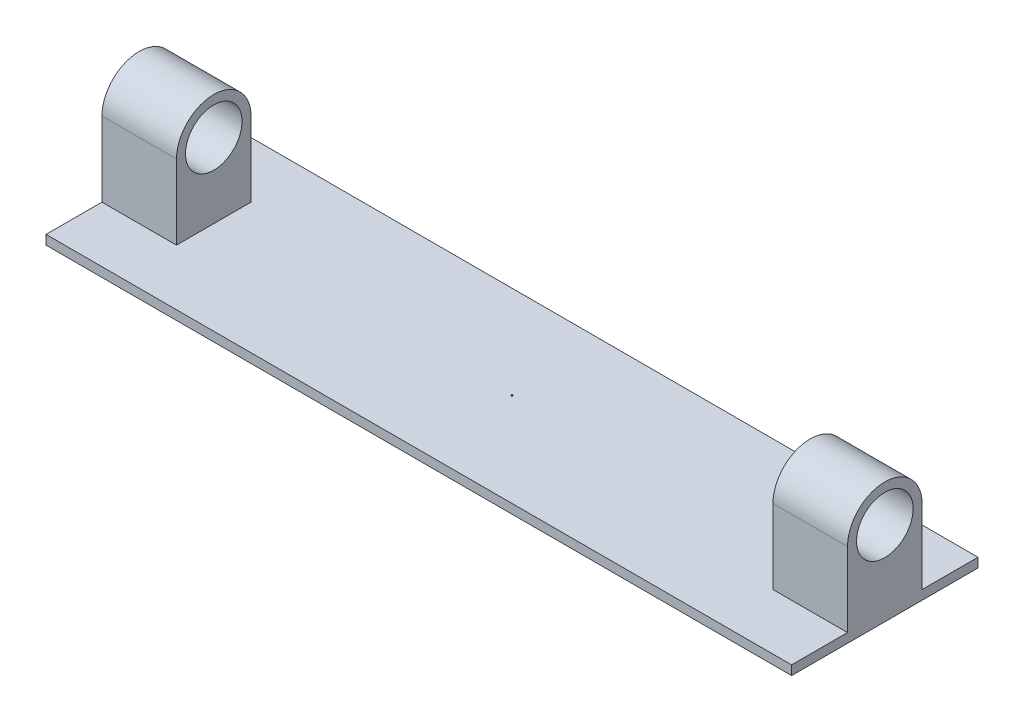
from build123d import *

# Parameters (mm, degrees)
SKETCH1_W           = 400
SKETCH1_H           = 100
BOSS_EXTRUDE1_DEPTH = 5
SKETCH6_R           = 15.180517927
BOSS_EXTRUDE2_DEPTH = 40
SKETCH7_R           = 0.320199733
BOSS_EXTRUDE3_DEPTH = 0.5


with BuildPart() as part:
    # Sketch1 → Boss-Extrude1 (new body)
    with BuildSketch(Plane(origin=(0, 0, 0), x_dir=(1, 0, 0), z_dir=(0, 1, 0))):
        Rectangle(SKETCH1_W, SKETCH1_H)
    extrude(amount=BOSS_EXTRUDE1_DEPTH)

    # Sketch6 → Boss-Extrude2 (add)
    with BuildSketch(Plane(origin=(200, 0, 0), x_dir=(0, 0, -1), z_dir=(1, 0, 0))):
        with BuildLine():
            Line((-20, 45), (-20, 5))
            Line((-20, 5), (20, 5))
            Line((20, 5), (20, 45))
            ThreePointArc((20, 45), (0, 65), (-20, 45))
        make_face()
        with Locations((0, 45)):
            Circle(SKETCH6_R, mode=Mode.SUBTRACT)
    boss_extrude2 = extrude(amount=-BOSS_EXTRUDE2_DEPTH)

    # Mirror1: Boss-Extrude2 across plane
    add(boss_extrude2.mirror(Plane(origin=(0, 0, 0), x_dir=(0, 0, 1), z_dir=(1, 0, 0))))

    # Sketch7 → Boss-Extrude3 (add)
    with BuildSketch(Plane(origin=(0, 5, 0), x_dir=(1, 0, 0), z_dir=(0, 1, 0))):
        Circle(SKETCH7_R)
    extrude(amount=BOSS_EXTRUDE3_DEPTH)


solid = part.part
